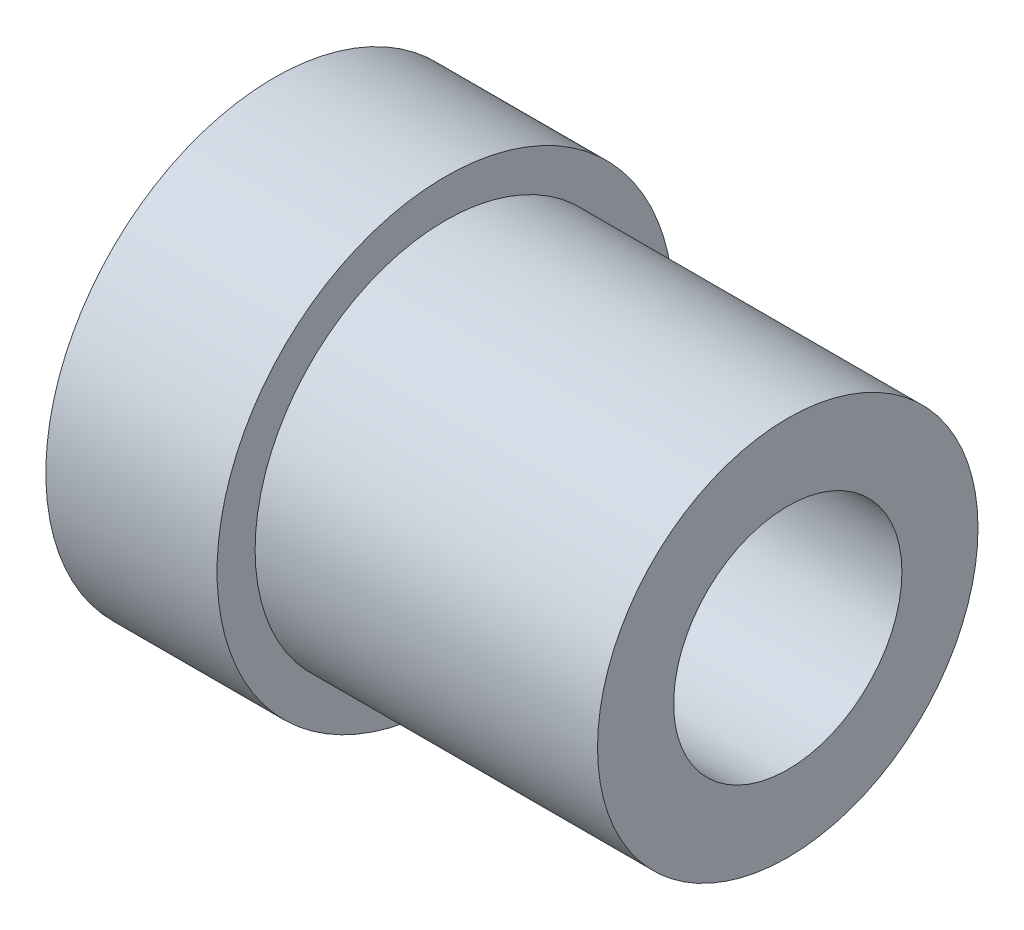
from build123d import *

# Parameters (mm, degrees)
SKETCH1_R           = 6
SKETCH1_R_2         = 3
BOSS_EXTRUDE1_DEPTH = 4.5
SKETCH2_R           = 5
SKETCH2_R_2         = 3
BOSS_EXTRUDE2_DEPTH = 9


with BuildPart() as part:
    # Sketch1 → Boss-Extrude1 (new body)
    with BuildSketch(Plane(origin=(0, 0, 0), x_dir=(0, 0, -1), z_dir=(1, 0, 0))):
        Circle(SKETCH1_R)
        Circle(SKETCH1_R_2, mode=Mode.SUBTRACT)
    extrude(amount=BOSS_EXTRUDE1_DEPTH)

    # Sketch2 → Boss-Extrude2 (add)
    with BuildSketch(Plane(origin=(4.5, 0, 0), x_dir=(0, 0, -1), z_dir=(1, 0, 0))):
        Circle(SKETCH2_R)
        Circle(SKETCH2_R_2, mode=Mode.SUBTRACT)
    extrude(amount=BOSS_EXTRUDE2_DEPTH)


solid = part.part
